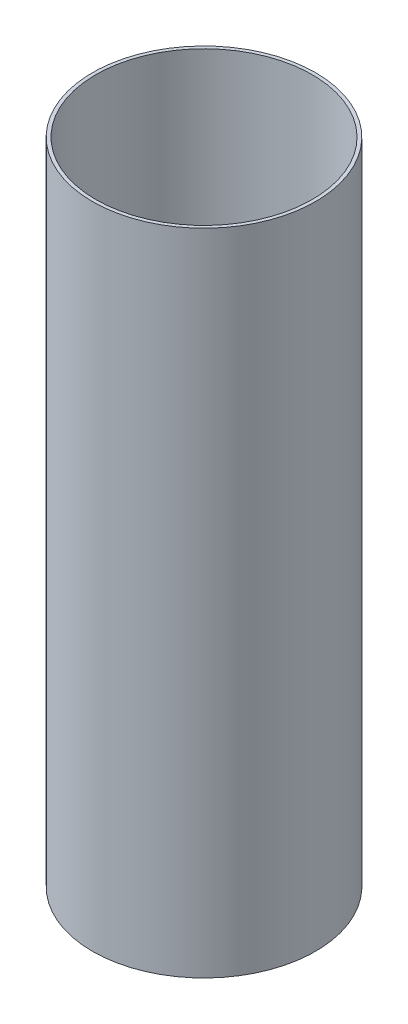
from build123d import *

# Parameters (mm, degrees)
SKETCH1_R           = 104.775
SKETCH1_R_2         = 101.6
BOSS_EXTRUDE1_DEPTH = 609.6


with BuildPart() as part:
    # Sketch1 → Boss-Extrude1 (new body)
    with BuildSketch(Plane(origin=(0, 0, 0), x_dir=(1, 0, 0), z_dir=(0, 1, 0))):
        Circle(SKETCH1_R)
        Circle(SKETCH1_R_2, mode=Mode.SUBTRACT)
    extrude(amount=BOSS_EXTRUDE1_DEPTH)


solid = part.part
